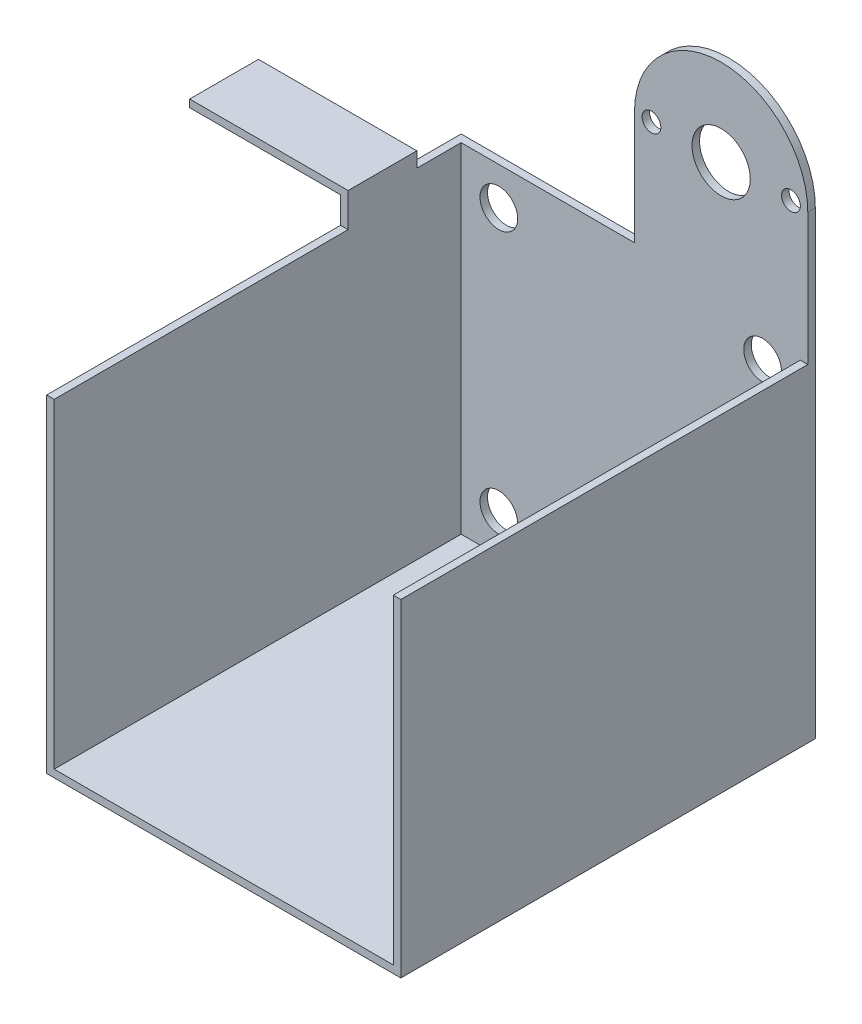
from build123d import *

# Parameters (mm, degrees)
SKETCH1_R           = 7.736199
SKETCH1_R_2         = 5
SKETCH1_R_3         = 2.5
BOSS_EXTRUDE1_DEPTH = 2
BOSS_EXTRUDE4_START = 21.349633
SKETCH2_W           = 92
SKETCH2_H           = 110
BOSS_EXTRUDE4_DEPTH = 2
SKETCH4_W           = 110
SKETCH4_H           = 87
BOSS_EXTRUDE5_DEPTH = 2
BOSS_EXTRUDE6_START = -165.340784
BOSS_EXTRUDE6_DEPTH = 2
BOSS_EXTRUDE8_START = 115.349633
SKETCH7_W           = 42.046546
SKETCH7_H           = 18.25
BOSS_EXTRUDE8_DEPTH = 2


with BuildPart() as part:
    # Sketch1 → Boss-Extrude1 (new body)
    with BuildSketch(Plane.XY):
        with BuildLine():
            Line((-73.340784, 141.349633), (-73.340784, 21.349633))
            Line((-73.340784, 21.349633), (-119.340784, 21.349633))
            Line((-119.340784, 21.349633), (-165.340784, 21.349633))
            Line((-165.340784, 21.349633), (-165.340784, 31.349633))
            Line((-165.340784, 31.349633), (-165.340784, 111.349633))
            Line((-165.340784, 111.349633), (-119.340784, 111.349633))
            Line((-119.340784, 111.349633), (-119.340784, 141.349633))
            ThreePointArc((-119.340784, 141.349633), (-96.340784, 164.349633), (-73.340784, 141.349633))
        make_face()
        with Locations((-96.340784, 141.349633)):
            Circle(SKETCH1_R, mode=Mode.SUBTRACT)
        with Locations((-85.340784, 101.349633)):
            Circle(SKETCH1_R_2, mode=Mode.SUBTRACT)
        with Locations((-77.819625, 141.785505)):
            Circle(SKETCH1_R_3, mode=Mode.SUBTRACT)
        with Locations((-114.840784, 141.349633)):
            Circle(SKETCH1_R_3, mode=Mode.SUBTRACT)
        with Locations((-155.340784, 101.349633)):
            Circle(SKETCH1_R_2, mode=Mode.SUBTRACT)
        with Locations((-85.340784, 31.349633)):
            Circle(SKETCH1_R_2, mode=Mode.SUBTRACT)
        with Locations((-155.340784, 31.349633)):
            Circle(SKETCH1_R_2, mode=Mode.SUBTRACT)
    extrude(amount=BOSS_EXTRUDE1_DEPTH)



with BuildPart() as body_2:
    # Sketch2 → Boss-Extrude4 (new body)
    with BuildSketch(Plane(origin=(0, 0, 0), x_dir=(1, 0, 0), z_dir=(0, 1, 0)).offset(BOSS_EXTRUDE4_START)):
        with Locations((-119.340784, -55)):
            Rectangle(SKETCH2_W, SKETCH2_H)
    extrude(amount=-BOSS_EXTRUDE4_DEPTH)


with BuildPart() as part_1:
    add(part.part)

    add(body_2.part)  # Boss-Extrude5 merges body 2
    # Sketch4 → Boss-Extrude5 (add)
    with BuildSketch(Plane(origin=(-73.340784, 0, 0), x_dir=(0, 0, -1), z_dir=(1, 0, 0))):
        with Locations((-55, 62.849633)):
            Rectangle(SKETCH4_W, SKETCH4_H)
    extrude(amount=-BOSS_EXTRUDE5_DEPTH)

    # Sketch5 → Boss-Extrude6 (add)
    with BuildSketch(Plane(origin=(0, 0, 0), x_dir=(0, 0, -1), z_dir=(1, 0, 0)).offset(BOSS_EXTRUDE6_START)):
        Polygon((0, 19.349633), (-110, 19.349633), (-110, 106.349633), (-32, 106.349633), (-32, 115.349633), (-13.75, 115.349633), (-13.75, 111.349633), (0, 111.349633), (0, 106.349633), align=None)
    extrude(amount=-BOSS_EXTRUDE6_DEPTH)

    # Sketch7 → Boss-Extrude8 (add)
    with BuildSketch(Plane(origin=(0, 0, 0), x_dir=(1, 0, 0), z_dir=(0, 1, 0)).offset(BOSS_EXTRUDE8_START)):
        with Locations((-186.364057, -22.875)):
            Rectangle(SKETCH7_W, SKETCH7_H)
    extrude(amount=-BOSS_EXTRUDE8_DEPTH)


solid = part_1.part
